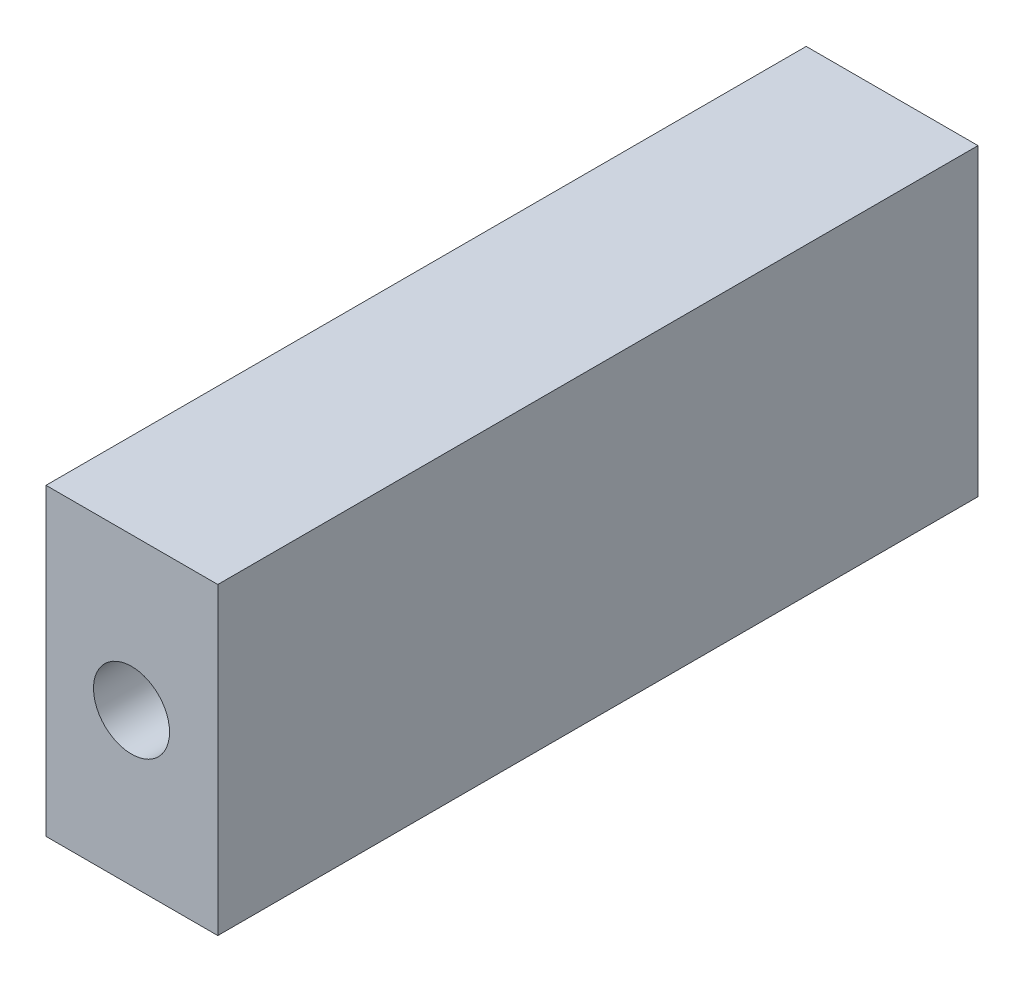
from build123d import *

# Parameters (mm, degrees)
SKETCH2_W           = 2.26
SKETCH2_H           = 4
BOSS_EXTRUDE1_DEPTH = 10
SKETCH3_R           = 0.5
CUT_EXTRUDE1_DEPTH  = 5


with BuildPart() as part:
    # Sketch2 → Boss-Extrude1 (new body)
    with BuildSketch(Plane.XY):
        with Locations((1.13, 2)):
            Rectangle(SKETCH2_W, SKETCH2_H)
    extrude(amount=BOSS_EXTRUDE1_DEPTH)

    # Sketch3 → Cut-Extrude1 (cut)
    with BuildSketch(Plane.XY.offset(10)):
        with Locations((1.125, 2)):
            Circle(SKETCH3_R)
    extrude(amount=-CUT_EXTRUDE1_DEPTH, mode=Mode.SUBTRACT)


solid = part.part
